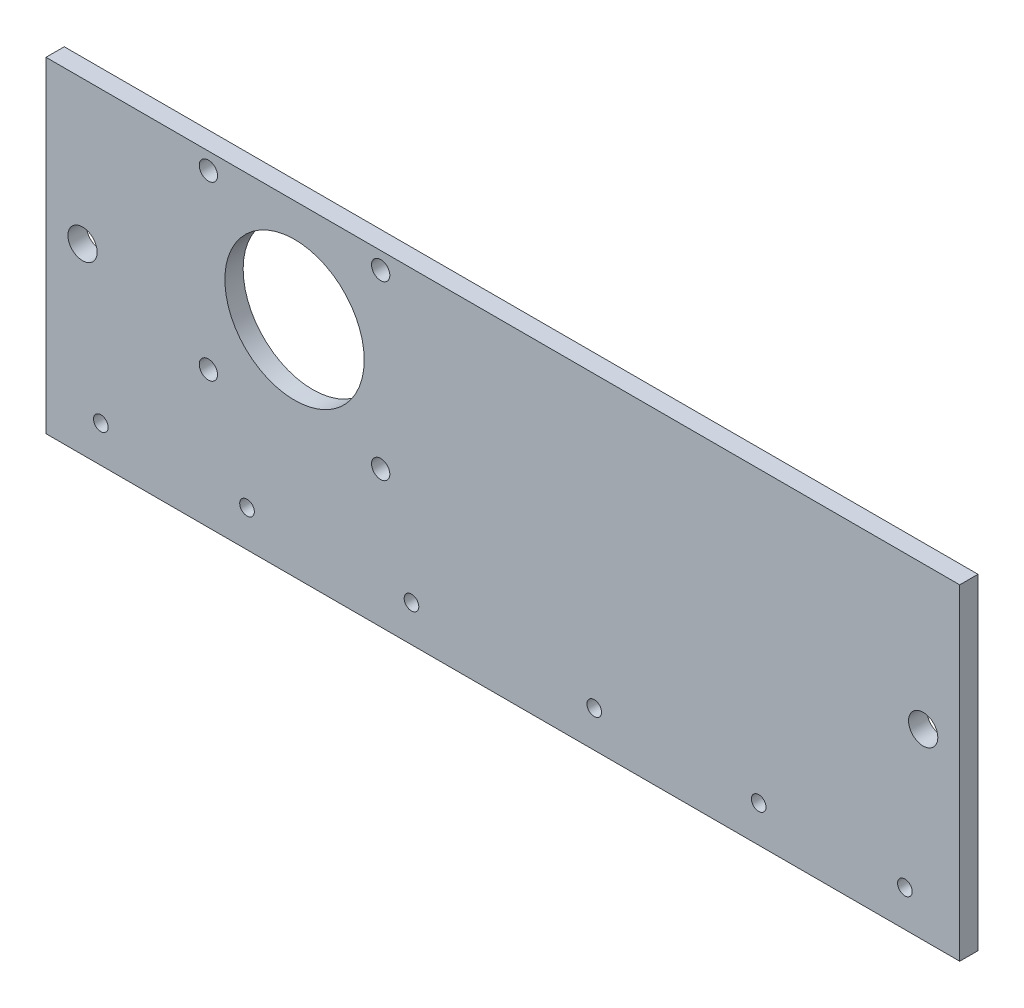
from build123d import *

# Parameters (mm, degrees)
SKIZZE1_W                       = 250
SKIZZE1_H                       = 89.2
AUFSATZ_LINEAR_AUSTRAGEN1_DEPTH = 5
SKIZZE2_R                       = 19.0625
SCHNITT_LINEAR_AUSTRAGEN1_DEPTH = 27
SKIZZE3_R                       = 2
SCHNITT_LINEAR_AUSTRAGEN2_DEPTH = 10
SKIZZE4_R                       = 4
SCHNITT_LINEAR_AUSTRAGEN3_DEPTH = 10
SKIZZE5_R                       = 2.5
SCHNITT_LINEAR_AUSTRAGEN4_DEPTH = 10
SKIZZE6_R                       = 2
SCHNITT_LINEAR_AUSTRAGEN5_DEPTH = 10


with BuildPart() as part:
    # Skizze1 → Aufsatz-Linear austragen1 (new body)
    with BuildSketch(Plane.XY):
        with Locations((125, 44.6)):
            Rectangle(SKIZZE1_W, SKIZZE1_H)
    extrude(amount=-AUFSATZ_LINEAR_AUSTRAGEN1_DEPTH)

    # Skizze2 → Schnitt-Linear austragen1 (cut)
    with BuildSketch(Plane.XY):
        with Locations((68, 61)):
            Circle(SKIZZE2_R)
    extrude(amount=-SCHNITT_LINEAR_AUSTRAGEN1_DEPTH, mode=Mode.SUBTRACT)

    # Skizze3 → Schnitt-Linear austragen2 (cut)
    with BuildSketch(Plane.XY):
        with Locations((15, 10)):
            Circle(SKIZZE3_R)
        with Locations((55, 10)):
            Circle(SKIZZE3_R)
        with Locations((195, 10)):
            Circle(SKIZZE3_R)
        with Locations((235, 10)):
            Circle(SKIZZE3_R)
        with Locations((150, 10)):
            Circle(SKIZZE3_R)
    extrude(amount=-SCHNITT_LINEAR_AUSTRAGEN2_DEPTH, mode=Mode.SUBTRACT)

    # Skizze4 → Schnitt-Linear austragen3 (cut)
    with BuildSketch(Plane.XY):
        with Locations((10, 50)):
            Circle(SKIZZE4_R)
        with Locations((240, 50)):
            Circle(SKIZZE4_R)
    extrude(amount=-SCHNITT_LINEAR_AUSTRAGEN3_DEPTH, mode=Mode.SUBTRACT)

    # Skizze5 → Schnitt-Linear austragen4 (cut)
    with BuildSketch(Plane.XY):
        with Locations((44.43, 84.57)):
            Circle(SKIZZE5_R)
        with Locations((91.57, 84.57)):
            Circle(SKIZZE5_R)
        with Locations((91.57, 37.43)):
            Circle(SKIZZE5_R)
        with Locations((44.43, 37.43)):
            Circle(SKIZZE5_R)
    extrude(amount=-SCHNITT_LINEAR_AUSTRAGEN4_DEPTH, mode=Mode.SUBTRACT)

    # Skizze6 → Schnitt-Linear austragen5 (cut)
    with BuildSketch(Plane.XY):
        with Locations((100, 10)):
            Circle(SKIZZE6_R)
    extrude(amount=-SCHNITT_LINEAR_AUSTRAGEN5_DEPTH, mode=Mode.SUBTRACT)


solid = part.part
